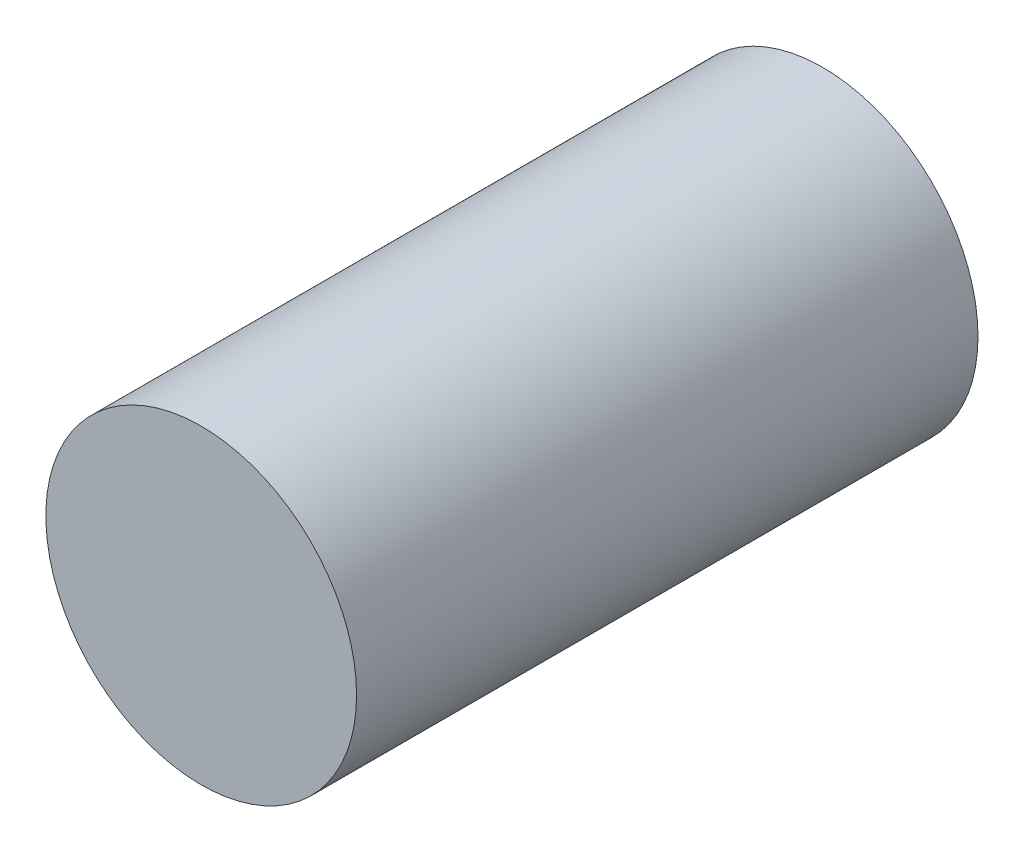
from build123d import *

# Parameters (mm, degrees)
SKETCH1_R           = 7.5
BOSS_EXTRUDE1_DEPTH = 30


with BuildPart() as part:
    # Sketch1 → Boss-Extrude1 (new body)
    with BuildSketch(Plane.XY):
        with Locations((475, -150)):
            Circle(SKETCH1_R)
    extrude(amount=BOSS_EXTRUDE1_DEPTH)


solid = part.part
